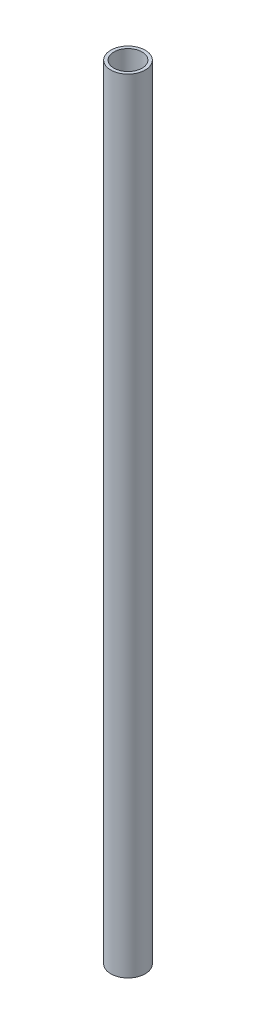
from build123d import *

# Parameters (mm, degrees)
SKETCH_1_R          = 11
EXTRUDE_1_DEPTH     = 20
SKETCH_2_R          = 11
EXTRUDE_2_DEPTH     = 480
SKETCH_4_R          = 9
CUT_EXTRUDE_1_DEPTH = 501


with BuildPart() as part:
    # 草图1 → 凸台-拉伸1 (new body)
    with BuildSketch(Plane(origin=(0, 0, 0), x_dir=(1, 0, 0), z_dir=(0, 1, 0))):
        Circle(SKETCH_1_R)
    extrude(amount=EXTRUDE_1_DEPTH)

    # 草图2 → 凸台-拉伸2 (add)
    with BuildSketch(Plane(origin=(0, 20, 0), x_dir=(1, 0, 0), z_dir=(0, 1, 0))):
        Circle(SKETCH_2_R)
    extrude(amount=EXTRUDE_2_DEPTH)

    # 草图4 → 切除-拉伸1 (cut, through all)
    with BuildSketch(Plane.XZ):
        Circle(SKETCH_4_R)
    extrude(amount=-CUT_EXTRUDE_1_DEPTH, mode=Mode.SUBTRACT)


solid = part.part
